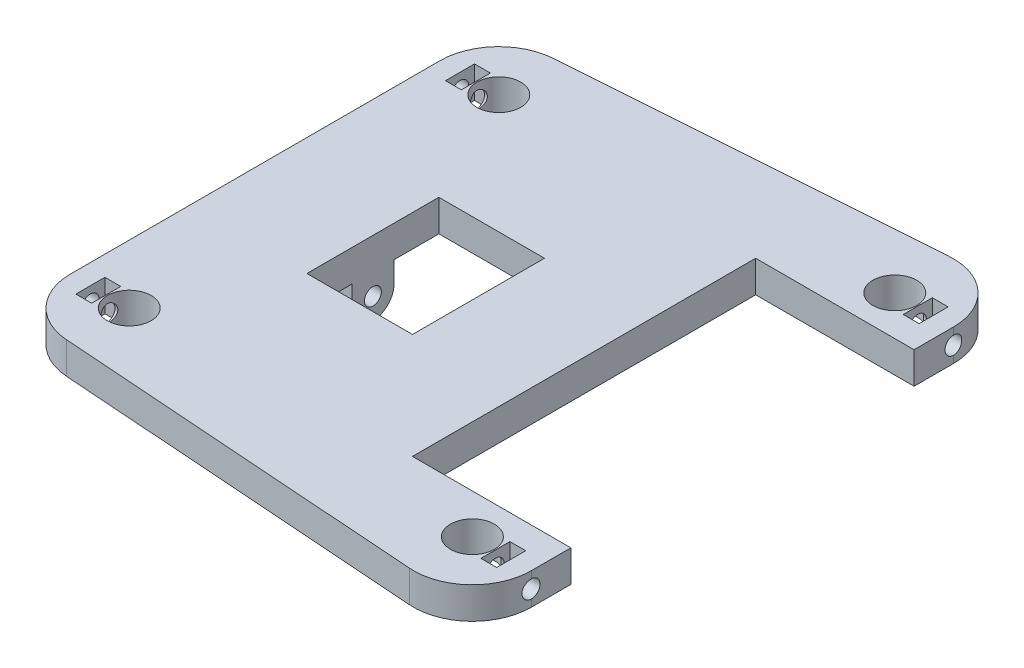
from build123d import *

# Parameters (mm, degrees)
ESBO_O2_R                = 4.15
ESBO_O2_W                = 3
ESBO_O2_H                = 5.5
ESBO_O2_W_2              = 20
ESBO_O2_H_2              = 25
RESSALTO_EXTRUS_O1_DEPTH = 6
ESBO_O4_R                = 1.6
RESSALTO_EXTRUS_O2_DEPTH = 4
RESSALTO_EXTRUS_O3_START = 20
ESBO_O4_2_R              = 1.6
RESSALTO_EXTRUS_O3_DEPTH = 4
CORTE_EXTRUS_O2_START    = -1
ESBO_O7_R                = 1.65
CORTE_EXTRUS_O2_DEPTH    = 8.8
CORTE_EXTRUS_O3_START    = -1
ESBO_O8_R                = 1.65
CORTE_EXTRUS_O3_DEPTH    = 8.8


with BuildPart() as part:
    # Esboço2 → Ressalto-extrusão1 (new body)
    with BuildSketch(Plane(origin=(0, 0, 0), x_dir=(1, 0, 0), z_dir=(0, 1, 0))):
        with BuildLine():
            Line((-0.794404607, 46.121664503), (69.205595393, 51.121664503))
            ThreePointArc((69.205595393, 51.121664503), (77.59818691, 48.160273015), (81.15, 40))
            Line((81.15, 40), (81.15, 32.5))
            Line((81.15, 32.5), (51.15, 32.5))
            Line((51.15, 32.5), (51.15, -32.5))
            Line((51.15, -32.5), (81.15, -32.5))
            Line((81.15, -32.5), (81.15, -40))
            ThreePointArc((81.15, -40), (77.59818691, -48.160273015), (69.205595393, -51.121664503))
            Line((69.205595393, -51.121664503), (-0.794404607, -46.121664503))
            ThreePointArc((-0.794404607, -46.121664503), (-8.160273015, -42.59818691), (-11.15, -35))
            Line((-11.15, -35), (-11.15, 35))
            ThreePointArc((-11.15, 35), (-8.160273015, 42.59818691), (-0.794404607, 46.121664503))
        make_face()
        with Locations((0, 35)):
            Circle(ESBO_O2_R, mode=Mode.SUBTRACT)
        with Locations((70, 40)):
            Circle(ESBO_O2_R, mode=Mode.SUBTRACT)
        with Locations((70, -40)):
            Circle(ESBO_O2_R, mode=Mode.SUBTRACT)
        with Locations((0, -35)):
            Circle(ESBO_O2_R, mode=Mode.SUBTRACT)
        with Locations((-5.85, 35)):
            Rectangle(ESBO_O2_W, ESBO_O2_H, mode=Mode.SUBTRACT)
        with Locations((75.85, 40)):
            Rectangle(ESBO_O2_W, ESBO_O2_H, mode=Mode.SUBTRACT)
        with Locations((75.85, -40)):
            Rectangle(ESBO_O2_W, ESBO_O2_H, mode=Mode.SUBTRACT)
        with Locations((-5.85, -35)):
            Rectangle(ESBO_O2_W, ESBO_O2_H, mode=Mode.SUBTRACT)
        with Locations((21.15, 0)):
            Rectangle(ESBO_O2_W_2, ESBO_O2_H_2, mode=Mode.SUBTRACT)
    extrude(amount=RESSALTO_EXTRUS_O1_DEPTH)

    # Esboço4 → Ressalto-extrusão2 (add)
    with BuildSketch(Plane(origin=(11.15, 0, 0), x_dir=(0, 0, -1), z_dir=(1, 0, 0))):
        with BuildLine():
            Line((-4, -4), (-4, 0))
            Line((-4, 0), (4, 0))
            Line((4, 0), (4, -4))
            ThreePointArc((4, -4), (0, -8), (-4, -4))
        make_face()
        with Locations((0, -4)):
            Circle(ESBO_O4_R, mode=Mode.SUBTRACT)
    extrude(amount=-RESSALTO_EXTRUS_O2_DEPTH)

    # Esboço4<2> → Ressalto-extrusão3 (add)
    with BuildSketch(Plane(origin=(11.15, 0, 0), x_dir=(0, 0, -1), z_dir=(1, 0, 0)).offset(RESSALTO_EXTRUS_O3_START)):
        with BuildLine():
            Line((-4, -4), (-4, 0))
            Line((-4, 0), (4, 0))
            Line((4, 0), (4, -4))
            ThreePointArc((4, -4), (0, -8), (-4, -4))
        make_face()
        with Locations((0, -4)):
            Circle(ESBO_O4_2_R, mode=Mode.SUBTRACT)
    extrude(amount=RESSALTO_EXTRUS_O3_DEPTH)

    # Esboço7 → Corte-extrusão2 (cut)
    with BuildSketch(Plane(origin=(74.35, 0, 0), x_dir=(0, 0, -1), z_dir=(1, 0, 0)).offset(CORTE_EXTRUS_O2_START)):
        with Locations((40, 3)):
            Circle(ESBO_O7_R)
    corte_extrus_o2 = extrude(amount=CORTE_EXTRUS_O2_DEPTH, mode=Mode.SUBTRACT)

    # Esboço8 → Corte-extrusão3 (cut)
    with BuildSketch(Plane.ZY.offset(4.35).offset(CORTE_EXTRUS_O3_START)):
        with Locations((35, 3)):
            Circle(ESBO_O8_R)
    corte_extrus_o3 = extrude(amount=CORTE_EXTRUS_O3_DEPTH, mode=Mode.SUBTRACT)

    # Espelhar1: Corte-extrusão2, Corte-extrusão3 across plane
    add(corte_extrus_o2.mirror(Plane.XY), mode=Mode.SUBTRACT)
    add(corte_extrus_o3.mirror(Plane.XY), mode=Mode.SUBTRACT)


solid = part.part
